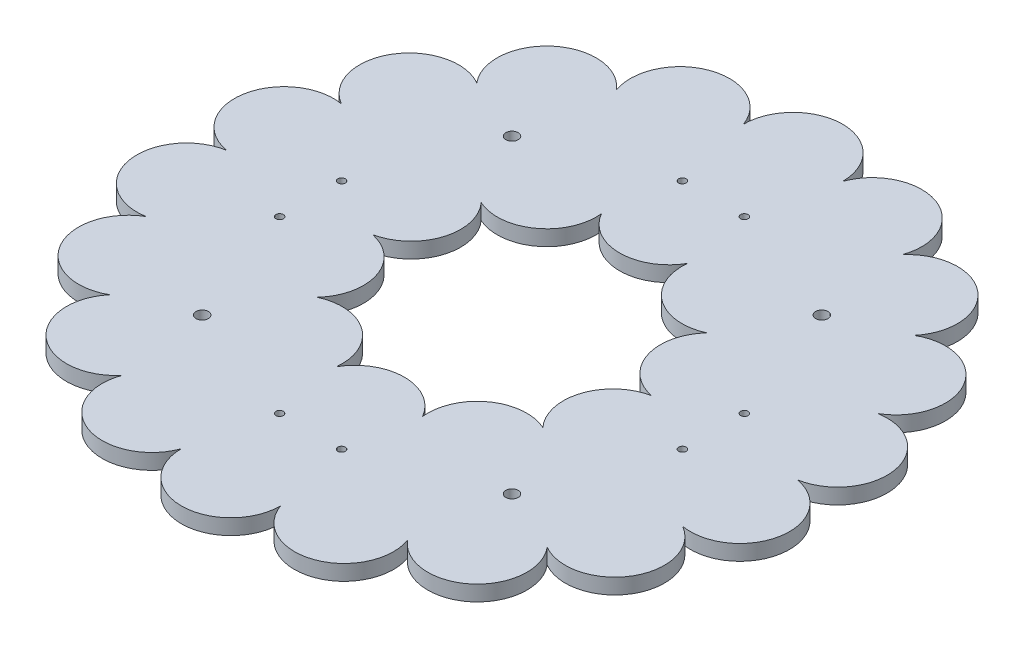
from build123d import *

# Parameters (mm, degrees)
SKETCH1_R           = 115.202561211
SKETCH1_R_2         = 64.402561211
BOSS_EXTRUDE1_DEPTH = 6.35
SKETCH2_R           = 20.32
BOSS_EXTRUDE2_DEPTH = 6.35
SKETCH3_R           = 2.54
SKETCH3_R_2         = 1.524
CUT_EXTRUDE1_DEPTH  = 7.35


with BuildPart() as part:
    # Sketch1 → Boss-Extrude1 (new body)
    with BuildSketch(Plane(origin=(0, 0, 0), x_dir=(1, 0, 0), z_dir=(0, 1, 0))):
        Circle(SKETCH1_R)
        Circle(SKETCH1_R_2, mode=Mode.SUBTRACT)
    extrude(amount=BOSS_EXTRUDE1_DEPTH)

    # Sketch2 → Boss-Extrude2 (add)
    with BuildSketch(Plane(origin=(0, 6.35, 0), x_dir=(1, 0, 0), z_dir=(0, 1, 0))):
        with Locations((0, 64.402561211)):
            Circle(SKETCH2_R)
        with Locations((0, 115.202561211)):
            Circle(SKETCH2_R)
        with Locations((37.85487569, 52.102766501)):
            Circle(SKETCH2_R)
        with Locations((61.250475506, 19.901485895)):
            Circle(SKETCH2_R)
        with Locations((61.250475506, -19.901485895)):
            Circle(SKETCH2_R)
        with Locations((37.85487569, -52.102766501)):
            Circle(SKETCH2_R)
        with Locations((0, -64.402561211)):
            Circle(SKETCH2_R)
        with Locations((-37.85487569, -52.102766501)):
            Circle(SKETCH2_R)
        with Locations((-61.250475506, -19.901485895)):
            Circle(SKETCH2_R)
        with Locations((-61.250475506, 19.901485895)):
            Circle(SKETCH2_R)
        with Locations((-37.85487569, 52.102766501)):
            Circle(SKETCH2_R)
        with Locations((39.401596497, 108.254996665)):
            Circle(SKETCH2_R)
        with Locations((74.05077895, 88.250281849)):
            Circle(SKETCH2_R)
        with Locations((99.768344589, 57.601280605)):
            Circle(SKETCH2_R)
        with Locations((113.452375447, 20.004714817)):
            Circle(SKETCH2_R)
        with Locations((113.452375447, -20.004714817)):
            Circle(SKETCH2_R)
        with Locations((99.76834459, -57.601280605)):
            Circle(SKETCH2_R)
        with Locations((74.05077895, -88.250281849)):
            Circle(SKETCH2_R)
        with Locations((39.401596497, -108.254996665)):
            Circle(SKETCH2_R)
        with Locations((0, -115.202561211)):
            Circle(SKETCH2_R)
        with Locations((-39.401596497, -108.254996665)):
            Circle(SKETCH2_R)
        with Locations((-74.05077895, -88.250281849)):
            Circle(SKETCH2_R)
        with Locations((-99.768344589, -57.601280605)):
            Circle(SKETCH2_R)
        with Locations((-113.452375447, -20.004714817)):
            Circle(SKETCH2_R)
        with Locations((-113.452375447, 20.004714817)):
            Circle(SKETCH2_R)
        with Locations((-99.768344589, 57.601280605)):
            Circle(SKETCH2_R)
        with Locations((-74.05077895, 88.250281849)):
            Circle(SKETCH2_R)
        with Locations((-39.401596497, 108.254996665)):
            Circle(SKETCH2_R)
    extrude(amount=-BOSS_EXTRUDE2_DEPTH)

    # Sketch3 → Cut-Extrude1 (cut, through all)
    with BuildSketch(Plane(origin=(0, 6.35, 0), x_dir=(1, 0, 0), z_dir=(0, 1, 0))):
        with Locations((-63.5, 63.5)):
            Circle(SKETCH3_R)
        with Locations((-63.5, -63.5)):
            Circle(SKETCH3_R)
        with Locations((63.5, 63.5)):
            Circle(SKETCH3_R)
        with Locations((63.5, -63.5)):
            Circle(SKETCH3_R)
        with Locations((-12.7, 82.55)):
            Circle(SKETCH3_R_2)
        with Locations((12.7, 82.55)):
            Circle(SKETCH3_R_2)
        with Locations((82.55, 12.7)):
            Circle(SKETCH3_R_2)
        with Locations((82.55, -12.7)):
            Circle(SKETCH3_R_2)
        with Locations((12.7, -82.55)):
            Circle(SKETCH3_R_2)
        with Locations((-12.7, -82.55)):
            Circle(SKETCH3_R_2)
        with Locations((-82.55, -12.7)):
            Circle(SKETCH3_R_2)
        with Locations((-82.55, 12.7)):
            Circle(SKETCH3_R_2)
    extrude(amount=-CUT_EXTRUDE1_DEPTH, mode=Mode.SUBTRACT)


solid = part.part
